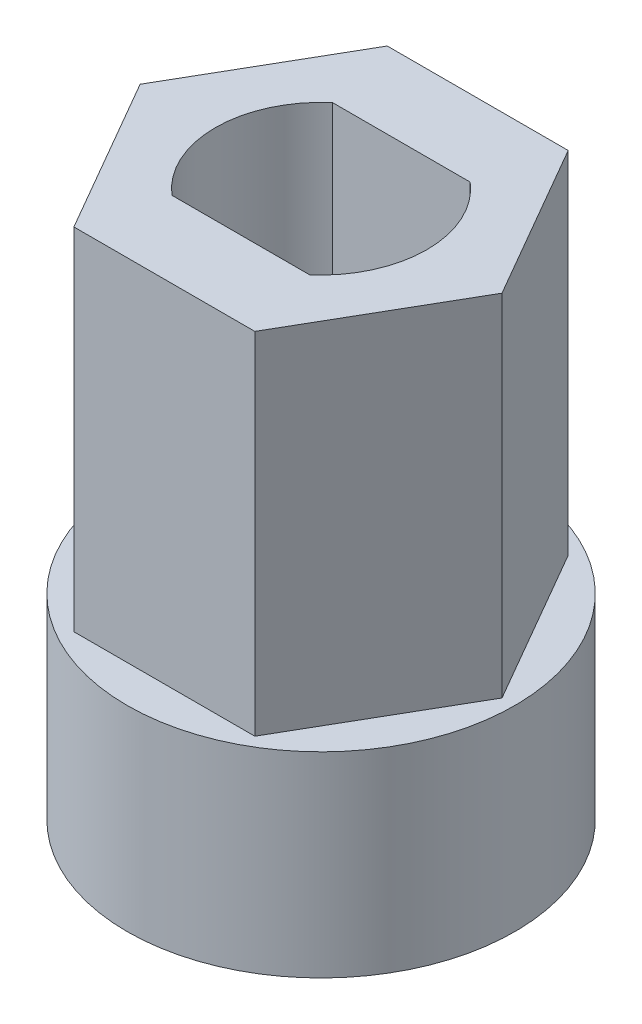
from build123d import *

# Parameters (mm, degrees)
BOSS_EXTRUDE1_DEPTH = 8.95
BOSS_EXTRUDE2_START = -5
SKETCH1_3_R         = 4.95
BOSS_EXTRUDE2_DEPTH = 5


with BuildPart() as part:
    # Sketch1 → Boss-Extrude1 (new body)
    with BuildSketch(Plane(origin=(0, 0, 0), x_dir=(1, 0, 0), z_dir=(0, 1, 0))):
        Polygon((4.618802154, 0), (2.309401077, 4), (-2.309401077, 4), (-4.618802154, 0), (-2.309401077, -4), (2.309401077, -4), align=None)
        with BuildLine():
            ThreePointArc((-1.757128339, -2.05), (-2.7, 0), (-1.757128339, 2.05))
            Line((-1.757128339, 2.05), (1.757128339, 2.05))
            ThreePointArc((1.757128339, 2.05), (2.7, 0), (1.757128339, -2.05))
            Line((1.757128339, -2.05), (-1.757128339, -2.05))
        make_face(mode=Mode.SUBTRACT)
    extrude(amount=BOSS_EXTRUDE1_DEPTH)

    # Sketch1_3 → Boss-Extrude2 (add)
    with BuildSketch(Plane(origin=(0, 0, 0), x_dir=(1, 0, 0), z_dir=(0, 1, 0)).offset(BOSS_EXTRUDE2_START)):
        Circle(SKETCH1_3_R)
        with BuildLine():
            ThreePointArc((-1.757128339, -2.05), (-2.7, 0), (-1.757128339, 2.05))
            Line((-1.757128339, 2.05), (1.757128339, 2.05))
            ThreePointArc((1.757128339, 2.05), (2.7, 0), (1.757128339, -2.05))
            Line((1.757128339, -2.05), (-1.757128339, -2.05))
        make_face(mode=Mode.SUBTRACT)
    extrude(amount=BOSS_EXTRUDE2_DEPTH)


solid = part.part
